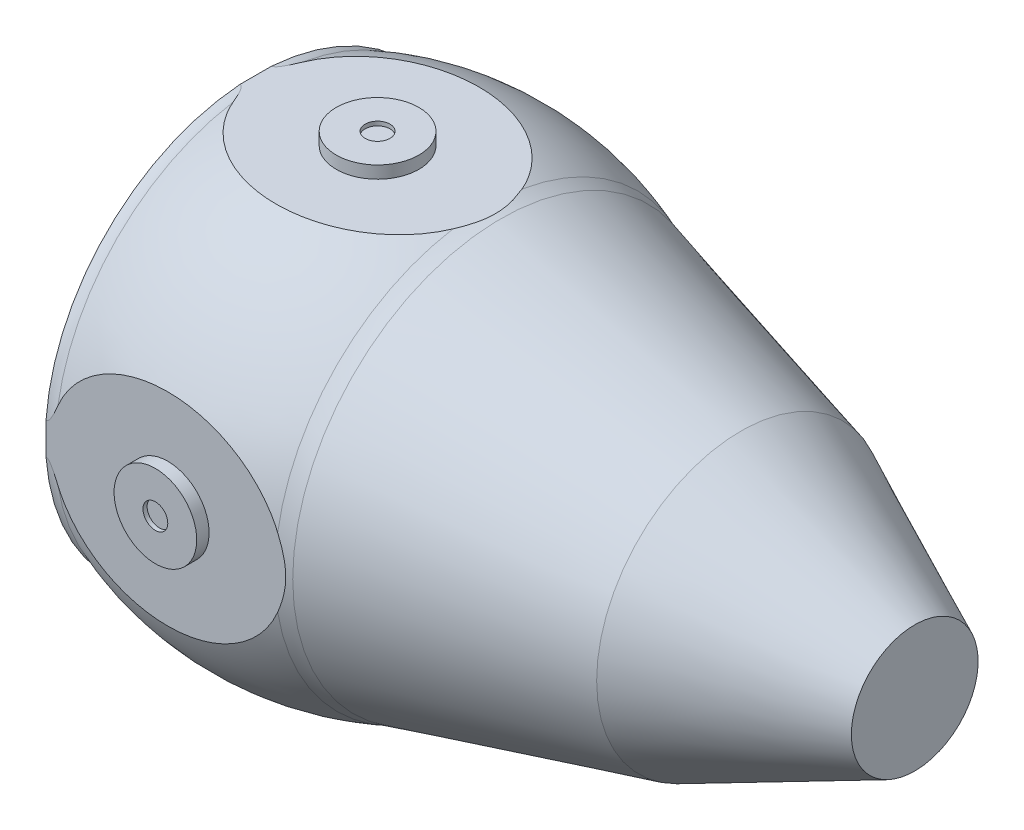
from build123d import *

# Parameters (mm, degrees)
ESCALA1_SCALE               = 0.2
PADR_OCIRCULAR1_COUNT       = 4
FURO_COM_FOLGA_DE_M61_D     = 6.6
FURO_COM_FOLGA_DE_M61_DEPTH = 19.342621622
FURO_COM_FOLGA_DE_M61_TIP   = 1.982840043


with BuildPart() as part:
    # Esboço1 → Revolução1 (revolve)
    with BuildSketch(Plane.XY, mode=Mode.PRIVATE) as revolu_o1_sk:
        with BuildLine():
            Line((3250.53685571, 0), (3250.53685571, 383.5))
            Line((3250.53685571, 383.5), (2198.53685571, 873))
            Line((2198.53685571, 873), (746.53685571, 1260))
            ThreePointArc((746.53685571, 1260), (705.413382944, 1272.149939556), (665, 1286.485891657))
            ThreePointArc((665, 1286.485891657), (0, 1410.13859172), (-665, 1286.485891657))
            ThreePointArc((-665, 1286.485891657), (-700.329808436, 1276.488395428), (-736.891891892, 1273.118032191))
            Line((-736.891891892, 1273.118032191), (-736.891891892, 1244.476357536))
            Line((-736.891891892, 1244.476357536), (41.718108108, 1244.476357536))
            Line((41.718108108, 1244.476357536), (41.718108108, 1164.476357536))
            Line((41.718108108, 1164.476357536), (71.718108108, 1164.476357536))
            Line((71.718108108, 1164.476357536), (71.718108108, 1244.476357536))
            Line((71.718108108, 1244.476357536), (746.53685571, 1244.476357536))
            Line((746.53685571, 1244.476357536), (1303.338284236, 1096.072671007))
            Line((1303.338284236, 1096.072671007), (2193.402058482, 858.844929525))
            Line((2193.402058482, 858.844929525), (3235.53685571, 373.935249636))
            Line((3235.53685571, 373.935249636), (3235.53685571, 0))
            Line((3235.53685571, 0), (3250.53685571, 0))
        make_face()
    revolve(revolu_o1_sk.sketch.rotate(Axis((-169.437422306, 0, 0), (1, 0, 0)), 90), axis=Axis((-169.437422306, 0, 0), (1, 0, 0)))


with BuildPart() as part_1:
    # Escala1: scaled about (0, 0, 0)
    add(part.part.scale(ESCALA1_SCALE))

    # Esboço2 → Corte-Revolução9 (revolve, cut)
    with BuildSketch(Plane.XY, mode=Mode.PRIVATE) as corte_revolu_o9_sk:
        Polygon((15, 268.895271507), (15, 263.895271507), (0, 263.895271507), (0, 311.146389703), (175.532983409, 311.146389703), (175.532983409, 253.895271507), (50, 253.895271507), (50, 268.895271507), align=None)
    corte_revolu_o9 = revolve(corte_revolu_o9_sk.sketch.rotate(Axis((0, -141.14012245, 0), (0, 1, 0)), 90), axis=Axis((0, -141.14012245, 0), (0, 1, 0)), mode=Mode.SUBTRACT)

    # PadrãoCircular1: Corte-Revolução9 ×4 about axis
    padr_ocircular1_axis = Axis((0, 0, 0), (1, 0, 0))
    for i in range(1, PADR_OCIRCULAR1_COUNT):
        add(corte_revolu_o9.rotate(padr_ocircular1_axis, i * 360 / PADR_OCIRCULAR1_COUNT), mode=Mode.SUBTRACT)

    # Furo com folga de M61
    with Locations(Plane(origin=(14.343621622, 0, 0), x_dir=(0, 0, -1), z_dir=(1, 0, 0))):
        with Locations((0, 240.895271507), (240.895271507, 0), (0, -240.895271507), (-240.895271507, 0), (0, 0)):
            Hole(FURO_COM_FOLGA_DE_M61_D / 2, depth=FURO_COM_FOLGA_DE_M61_DEPTH)
            with Locations((0, 0, -(FURO_COM_FOLGA_DE_M61_DEPTH + FURO_COM_FOLGA_DE_M61_TIP / 2))):  # 118° drill point
                Cone(0, FURO_COM_FOLGA_DE_M61_D / 2, FURO_COM_FOLGA_DE_M61_TIP, mode=Mode.SUBTRACT)


solid = part_1.part
